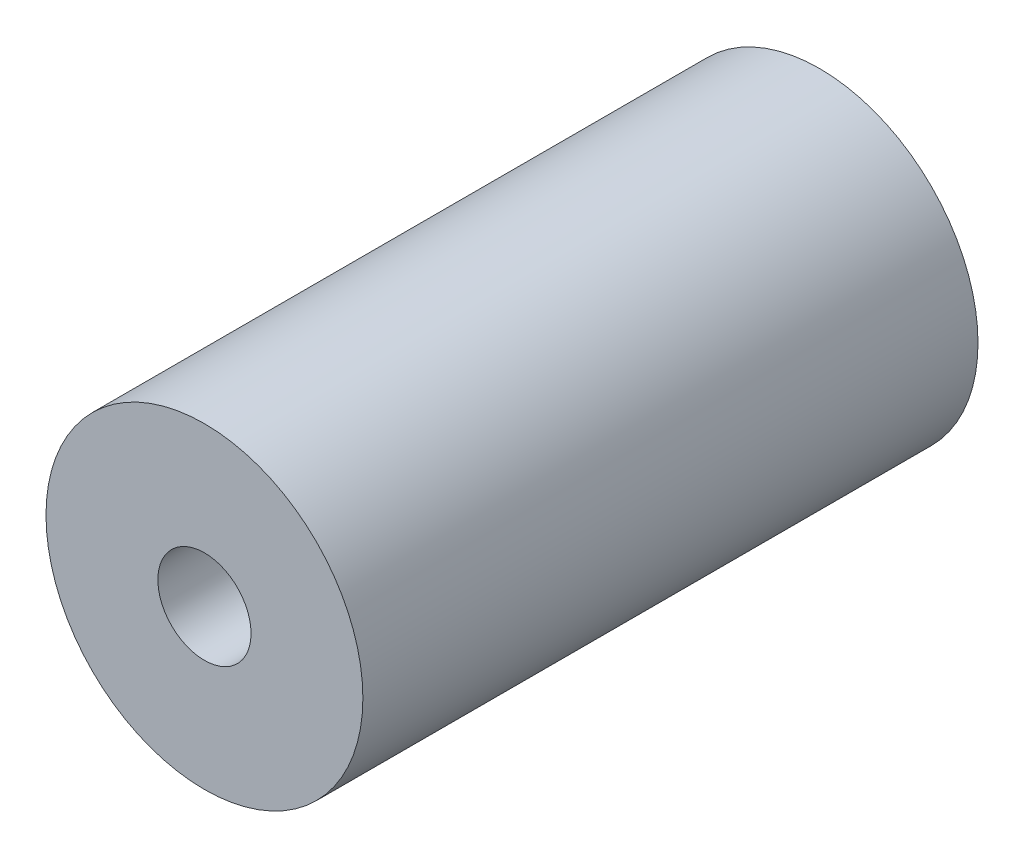
from build123d import *

# Parameters (mm, degrees)
CROQUIS1_R              = 17
CROQUIS1_R_2            = 5
SALIENTE_EXTRUIR1_DEPTH = 33


with BuildPart() as part:
    # Croquis1 → Saliente-Extruir1 (new body, symmetric)
    with BuildSketch(Plane.XY):
        Circle(CROQUIS1_R)
        Circle(CROQUIS1_R_2, mode=Mode.SUBTRACT)
    extrude(amount=SALIENTE_EXTRUIR1_DEPTH, both=True)


solid = part.part
